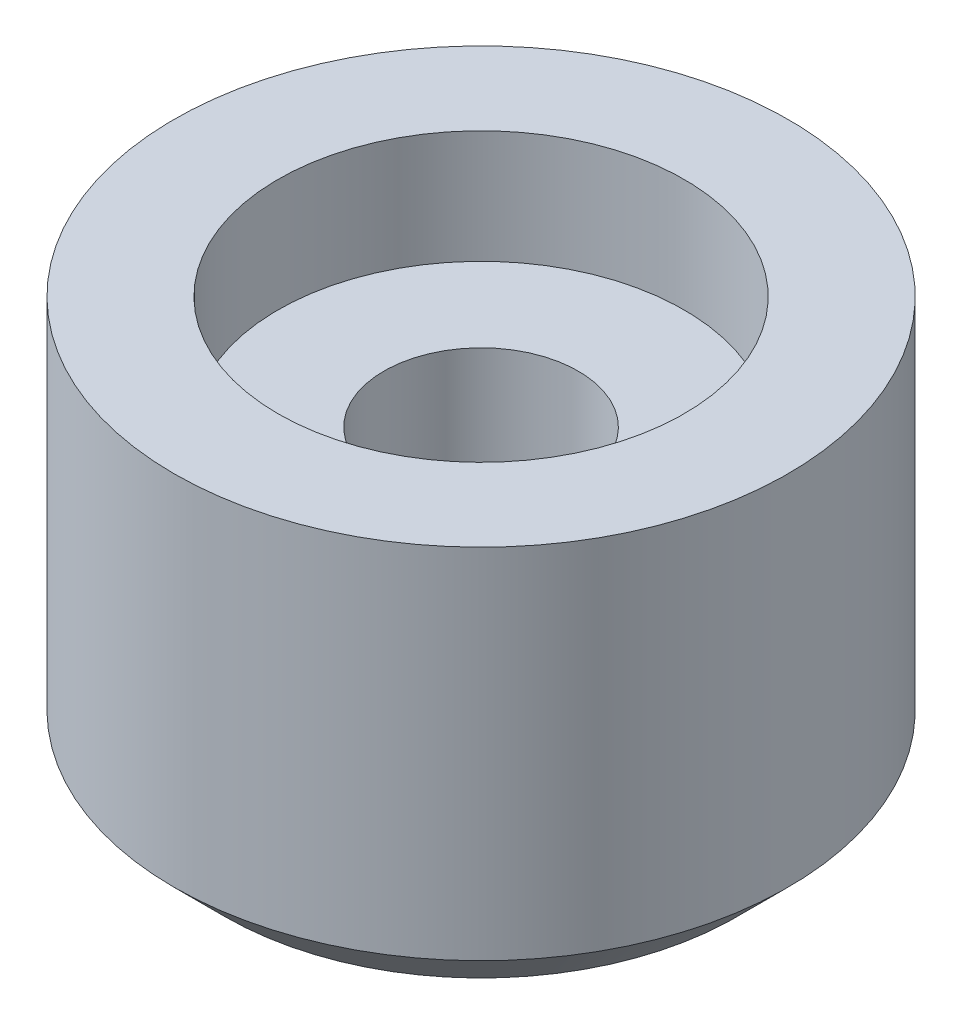
from build123d import *

# Parameters (mm, degrees)
SKETCH1_R                                           = 6
BOSS_EXTRUDE1_DEPTH                                 = 8
CBORE_FOR_6_BINDING_HEAD_MACHINE_SCREW2_D           = 3.7973
CBORE_FOR_6_BINDING_HEAD_MACHINE_SCREW2_CBORE_D     = 7.9375
CBORE_FOR_6_BINDING_HEAD_MACHINE_SCREW2_CBORE_DEPTH = 2.2098
CHAMFER1_SIZE                                       = 1


with BuildPart() as part:
    # Sketch1 → Boss-Extrude1 (new body)
    with BuildSketch(Plane(origin=(0, 0, 0), x_dir=(1, 0, 0), z_dir=(0, 1, 0))):
        Circle(SKETCH1_R)
    extrude(amount=BOSS_EXTRUDE1_DEPTH)

    # CBORE for #6 Binding Head Machine Screw2 (through all)
    with Locations(Plane(origin=(0, 8, 0), x_dir=(1, 0, 0), z_dir=(0, 1, 0))):
        with Locations((0, 0)):
            CounterBoreHole(CBORE_FOR_6_BINDING_HEAD_MACHINE_SCREW2_D / 2, CBORE_FOR_6_BINDING_HEAD_MACHINE_SCREW2_CBORE_D / 2, CBORE_FOR_6_BINDING_HEAD_MACHINE_SCREW2_CBORE_DEPTH)

    # Chamfer1
    chamfer1_edges = [part.edges().sort_by_distance(p)[0] for p in [
        (-6, 0, 0),
    ]]
    chamfer(chamfer1_edges, length=CHAMFER1_SIZE)


solid = part.part
